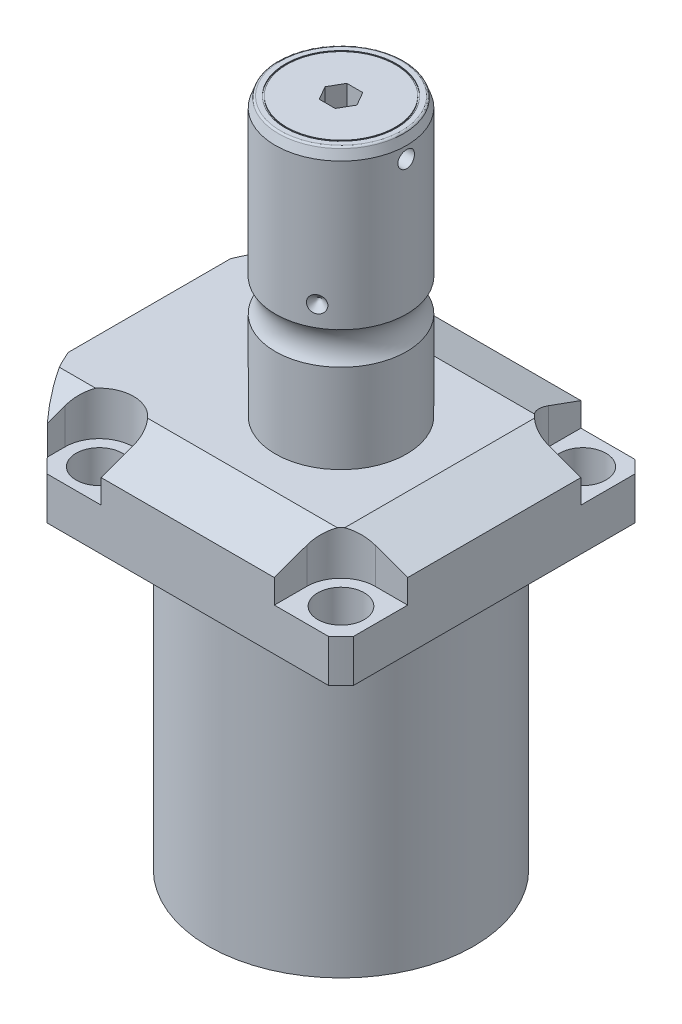
from build123d import *

# Parameters (mm, degrees)
SKETCH1_W               = 88.9
SKETCH1_H               = 99.9998
EXTRUDE1_DEPTH          = 113.919
SKETCH2_OUTSIDE_W       = 137.146
SKETCH2_OUTSIDE_H       = 126.046
SKETCH2_OUTSIDE_R       = 60.325
CUT_EXTRUDE1_DEPTH      = 114.919
SKETCH3_W               = 38.1
SKETCH3_H               = 88.9
FILLET1_R               = 0.381
CUT_EXTRUDE2_DEPTH      = 12.7
CUT_EXTRUDE9_START      = -56.5498
CUT_EXTRUDE9_DEPTH      = 101.9998
CUT_EXTRUDE7_DEPTH      = 45.45
CUT_EXTRUDE7_DEPTH_BACK = 45.45
SKETCH10_R              = 1.1811
SKETCH11_R              = 1.1811
SKETCH14_R              = 7.112
EXTRUDE2_DEPTH          = 1.27
SKETCH17_W              = 6.7437
SKETCH17_H              = 12.319
HOLE1_AT_2_COUNT        = 2
HOLE1_AT_2_PITCH        = 70.104
HOLE1_AT_3_COUNT        = 2
HOLE1_AT_3_PITCH        = 99.142028
HOLE1_AT_4_COUNT        = 2
HOLE1_AT_4_PITCH        = 70.104
CHAMFER1_SIZE           = 0.635
FILLET2_R               = 0.635
SKETCH21_R              = 16.129
SKETCH21_R_2            = 15.748
CUT_EXTRUDE10_DEPTH     = 0.254
CUT_EXTRUDE11_DEPTH     = 7.9756
CIRPATTERN1_COUNT       = 3
SKETCH24_W              = 3.81
SKETCH24_H              = 2.413


with BuildPart() as part:
    # Sketch1 → Extrude1 (new body)
    with BuildSketch(Plane.ZX):
        with Locations((0, -5.5499)):
            Rectangle(SKETCH1_W, SKETCH1_H)
    extrude(amount=EXTRUDE1_DEPTH)

    # Sketch2 outside → Cut-Extrude1 (cut, through all)
    with BuildSketch(Plane.XZ):
        with Locations((-5.55, 0)):
            Rectangle(SKETCH2_OUTSIDE_W, SKETCH2_OUTSIDE_H)
        Circle(SKETCH2_OUTSIDE_R, mode=Mode.SUBTRACT)
    extrude(amount=-CUT_EXTRUDE1_DEPTH, mode=Mode.SUBTRACT)

    # Sketch3 → Cut-Revolve1 (revolve, cut)
    with BuildSketch(Plane(origin=(0, 0, 0), x_dir=(0, 0, 1), z_dir=(1, 0, 0))):
        with Locations((57.5437, -44.45)):
            Rectangle(SKETCH3_W, SKETCH3_H)
    revolve(axis=Axis((0, 93.345, 0), (0, -1, 0)), mode=Mode.SUBTRACT)

    # Fillet1
    fillet1_edges = [part.edges().sort_by_distance(p)[0] for p in [
        (0, 88.9, -38.4937),
    ]]
    fillet(fillet1_edges, radius=FILLET1_R)

    # Sketch4 → Cut-Extrude2 (cut)
    with BuildSketch(Plane(origin=(0, 113.919, 0), x_dir=(-1, 0, 0), z_dir=(0, 1, 0))):
        with BuildLine():
            Line((-25.1206, -44.45), (-25.1206, -35.052))
            ThreePointArc((-25.1206, -35.052), (-28.02944, -28.02944), (-35.052, -25.1206))
            Line((-35.052, -25.1206), (-44.45, -25.1206))
            Line((-44.45, -25.1206), (-44.45, -44.45))
            Line((-44.45, -44.45), (-25.1206, -44.45))
        make_face()
        with BuildLine():
            Line((44.9834, -44.45), (25.1206, -44.45))
            Line((25.1206, -44.45), (25.1206, -35.052))
            ThreePointArc((25.1206, -35.052), (35.052, -25.1206), (44.9834, -35.052))
            Line((44.9834, -35.052), (44.9834, -44.45))
        make_face()
        with BuildLine():
            Line((25.1206, 44.45), (25.1206, 35.052))
            ThreePointArc((25.1206, 35.052), (35.052, 25.1206), (44.9834, 35.052))
            Line((44.9834, 35.052), (44.9834, 44.45))
            Line((44.9834, 44.45), (25.1206, 44.45))
        make_face()
        with BuildLine():
            Line((-35.052, 25.1206), (-44.45, 25.1206))
            Line((-44.45, 25.1206), (-44.45, 44.45))
            Line((-44.45, 44.45), (-25.1206, 44.45))
            Line((-25.1206, 44.45), (-25.1206, 35.052))
            ThreePointArc((-25.1206, 35.052), (-28.02944, 28.02944), (-35.052, 25.1206))
        make_face()
    extrude(amount=-CUT_EXTRUDE2_DEPTH, mode=Mode.SUBTRACT)

    # Sketch5 → Cut-Extrude9 (cut)
    with BuildSketch(Plane(origin=(0, 0, 0), x_dir=(0, 0, -1), z_dir=(1, 0, 0)).offset(CUT_EXTRUDE9_START)):
        Polygon((-28.575, 113.919), (-44.45, 108.140973), (-44.45, 113.919), align=None)
    cut_extrude9 = extrude(amount=CUT_EXTRUDE9_DEPTH, mode=Mode.SUBTRACT)

    # Mirror1: Cut-Extrude9 across plane
    add(cut_extrude9.mirror(Plane.XY), mode=Mode.SUBTRACT)

    # Sketch9 → Cut-Extrude7 (cut, two sides)
    with BuildSketch(Plane.XY) as cut_extrude7_sk:
        Polygon((28.575, 113.919), (44.45, 108.140973), (44.45, 113.919), align=None)
    extrude(amount=CUT_EXTRUDE7_DEPTH, mode=Mode.SUBTRACT)
    extrude(cut_extrude7_sk.sketch, amount=-CUT_EXTRUDE7_DEPTH_BACK, mode=Mode.SUBTRACT)

    # Sketch20 → Cut-Revolve4 (revolve, cut)
    with BuildSketch(Plane(origin=(-41.402, 88.9, -18.1102), x_dir=(0, 1, 0), z_dir=(1, 0, 0)), mode=Mode.PRIVATE) as cut_revolve4_sk:
        Polygon((0, 41.9227), (1.4478, 41.9227), (1.4478, 39.4716), (2.4638, 39.4716), (2.4638, 37.465), (13.4366, 37.465), (13.4366, 36.2204), (0, 36.2204), align=None)
    cut_revolve4 = revolve(cut_revolve4_sk.sketch.rotate(Axis((-41.402, 81.620305, 18.1102), (0, 1, 0)), 180), axis=Axis((-41.402, 81.620305, 18.1102), (0, 1, 0)), mode=Mode.SUBTRACT)  # turned: the seam where the file's is

    # Mirror10: Cut-Revolve4 across plane
    add(cut_revolve4.mirror(Plane.XY), mode=Mode.SUBTRACT)

    # S2D0007 → Cut-Revolve2 (revolve, cut)
    with BuildSketch(Plane(origin=(-55.5498, 101.9048, 12.9794), x_dir=(0, 1, 0), z_dir=(0, 0, 1)), mode=Mode.PRIVATE) as cut_revolve2_sk:
        Polygon((0, 0), (10.4775, 0), (10.4775, -0.254), (6.1849, -0.254), (5.642307, -2.8067), (4.9784, -3.470607), (4.9784, -14.224), (0, -14.224), align=None)
    revolve(cut_revolve2_sk.sketch.rotate(Axis((-40.6146, 101.9048, 12.9794), (-1, 0, 0)), 90), axis=Axis((-40.6146, 101.9048, 12.9794), (-1, 0, 0)), mode=Mode.SUBTRACT)  # turned: the seam where the file's is

    # Sketch13 → Cut-Revolve3 (revolve, cut)
    with BuildSketch(Plane(origin=(-55.5498, 101.9048, -12.9794), x_dir=(0, 1, 0), z_dir=(0, 0, 1)), mode=Mode.PRIVATE) as cut_revolve3_sk:
        Polygon((0, 0), (10.4775, 0), (10.4775, -0.254), (6.1849, -0.254), (5.642307, -2.8067), (4.9784, -3.470607), (4.9784, -14.224), (0, -14.224), align=None)
    revolve(cut_revolve3_sk.sketch.rotate(Axis((-40.6146, 101.9048, -12.9794), (-1, 0, 0)), 90), axis=Axis((-40.6146, 101.9048, -12.9794), (-1, 0, 0)), mode=Mode.SUBTRACT)  # turned: the seam where the file's is

    # Sketch14 → Extrude2 (add)
    with BuildSketch(Plane.ZY.offset(55.2958)):
        with Locations(Location((-12.9794, 101.9048, 0), (0, 0, 180))):  # turned: the seam where the file's is
            Circle(SKETCH14_R)
    extrude(amount=EXTRUDE2_DEPTH)

    # Sketch15 → Revolve3 (revolve)
    with BuildSketch(Plane(origin=(0, 0, 0), x_dir=(0, -1, 0), z_dir=(1, 0, 0)), mode=Mode.PRIVATE) as revolve3_sk:
        with BuildLine():
            Line((-113.919, 0), (-113.919, 19.05))
            Line((-113.919, 19.05), (-139.641106, 19.05))
            ThreePointArc((-139.641106, 19.05), (-144.3482, 17.5006), (-149.055294, 19.05))
            Line((-149.055294, 19.05), (-191.4144, 19.05))
            Line((-191.4144, 19.05), (-194.3354, 17.986843))
            Line((-194.3354, 17.986843), (-194.3354, 0))
            Line((-194.3354, 0), (-113.919, 0))
        make_face()
    revolve(revolve3_sk.sketch.rotate(Axis((0, 197.63613, 0), (0, -1, 0)), 180), axis=Axis((0, 197.63613, 0), (0, -1, 0)))  # turned: the seam where the file's is

    # Sketch17 → Hole1 (revolve, cut)
    with BuildSketch(Plane(origin=(35.052, 101.219, -35.052), x_dir=(0, 0, 1), z_dir=(1, 0, 0))):
        with Locations((3.37185, 6.1595)):
            Rectangle(SKETCH17_W, SKETCH17_H)
    hole1 = revolve(axis=Axis((35.052, -8.781, -35.052), (0, 1, 0)), mode=Mode.SUBTRACT)

    # Hole1 at 2: Hole1 ×2
    with Locations(*[(0, 0, i * HOLE1_AT_2_PITCH) for i in range(1, HOLE1_AT_2_COUNT)]):
        add(hole1, mode=Mode.SUBTRACT)

    # Hole1 at 3: Hole1 ×2
    with Locations(*[Vector(-0.707107, 0, 0.707107) * (i * HOLE1_AT_3_PITCH) for i in range(1, HOLE1_AT_3_COUNT)]):
        add(hole1, mode=Mode.SUBTRACT)

    # Hole1 at 4: Hole1 ×2
    with Locations(*[(-i * HOLE1_AT_4_PITCH, 0, 0) for i in range(1, HOLE1_AT_4_COUNT)]):
        add(hole1, mode=Mode.SUBTRACT)

    # Chamfer1
    chamfer1_edges = [part.edges().sort_by_distance(p)[0] for p in [
        (-41.402, 91.3638, 19.3548),
        (-41.402, 91.3638, -19.3548),
    ]]
    chamfer(chamfer1_edges, length=CHAMFER1_SIZE)

    # Fillet2
    fillet2_edges = [part.edges().sort_by_distance(p)[0] for p in [
        (0, 194.3354, -17.986843),
    ]]
    fillet(fillet2_edges, radius=FILLET2_R)

    # Sketch21 → Cut-Extrude10 (cut)
    with BuildSketch(Plane(origin=(0, 194.3354, 0), x_dir=(1, 0, 0), z_dir=(0, 1, 0))):
        with Locations(Location((0, 0, 0), (0, 0, 270))):  # turned: the seam where the file's is
            Circle(SKETCH21_R)
        with Locations(Location((0, 0, 0), (0, 0, 270))):  # turned: the seam where the file's is
            Circle(SKETCH21_R_2, mode=Mode.SUBTRACT)
    extrude(amount=-CUT_EXTRUDE10_DEPTH, mode=Mode.SUBTRACT)

    # Sketch22 → Cut-Extrude11 (cut)
    with BuildSketch(Plane(origin=(0, 194.3354, 0), x_dir=(1, 0, 0), z_dir=(0, 1, 0))):
        Polygon((4.618793, 0), (2.309396, 3.999992), (-2.309396, 3.999992), (-4.618793, 0), (-2.309396, -3.999992), (2.309396, -3.999992), align=None)
    extrude(amount=-CUT_EXTRUDE11_DEPTH, mode=Mode.SUBTRACT)

    # Sketch23 → Cut-Revolve5 (revolve, cut)
    with BuildSketch(Plane.XY, mode=Mode.PRIVATE) as cut_revolve5_sk:
        Polygon((-19.05, 157.4292), (-16.637, 155.0162), (-19.05, 155.0162), align=None)
    cut_revolve5 = revolve(cut_revolve5_sk.sketch.rotate(Axis((7.837338, 155.0162, 0), (-1, 0, 0)), 270), axis=Axis((7.837338, 155.0162, 0), (-1, 0, 0)), mode=Mode.SUBTRACT)  # turned: the seam where the file's is

    # CirPattern1: Cut-Revolve5 ×3 about axis
    cirpattern1_axis = Axis((0, 197.63613, 0), (0, 1, 0))
    for i in range(1, CIRPATTERN1_COUNT):
        add(cut_revolve5.rotate(cirpattern1_axis, i * 360 / CIRPATTERN1_COUNT), mode=Mode.SUBTRACT)

    # Sketch24 → Cut-Revolve6 (revolve, cut)
    with BuildSketch(Plane.XY, mode=Mode.PRIVATE) as cut_revolve6_sk:
        with Locations((17.145, 189.1919)):
            Rectangle(SKETCH24_W, SKETCH24_H)
    revolve(cut_revolve6_sk.sketch.rotate(Axis((3.251219, 187.9854, 0), (1, 0, 0)), 90), axis=Axis((3.251219, 187.9854, 0), (1, 0, 0)), mode=Mode.SUBTRACT)  # turned: the seam where the file's is


with BuildPart() as body_2:
    # Sketch10 → Revolve4 (revolve)
    with BuildSketch(Plane(origin=(-41.402, 88.9, -18.1102), x_dir=(0, 1, 0), z_dir=(1, 0, 0))):
        with Locations((0.2667, 4.5212)):
            Circle(SKETCH10_R)
    revolve(axis=Axis((-41.402, 87.86749, -18.1102), (0, 1, 0)))


with BuildPart() as body_3:
    # Sketch11 → Revolve2 (revolve)
    with BuildSketch(Plane(origin=(-41.402, 88.9, 18.1102), x_dir=(0, 1, 0), z_dir=(1, 0, 0)), mode=Mode.PRIVATE) as revolve2_sk:
        with Locations((0.2667, 4.5212)):
            Circle(SKETCH11_R)
    revolve(revolve2_sk.sketch.rotate(Axis((-41.402, 87.86749, 18.1102), (0, 1, 0)), 180), axis=Axis((-41.402, 87.86749, 18.1102), (0, 1, 0)))  # turned: the seam where the file's is


solid = Compound([part.part, body_2.part, body_3.part])
